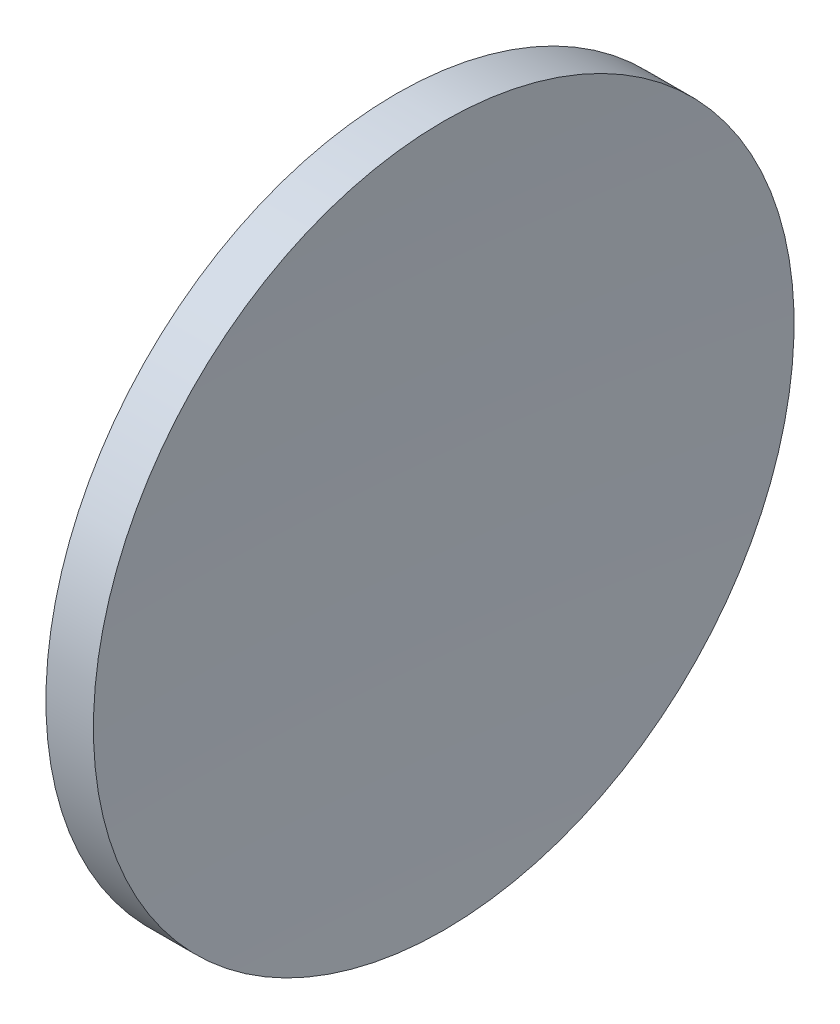
from build123d import *


with BuildPart() as part:
    # 草图1 → 旋转1 (revolve)
    with BuildSketch(Plane.XY):
        with BuildLine():
            Line((247.046493409, 155.433680942), (250.436344506, 155.433680942))
            ThreePointArc((250.436344506, 155.433680942), (249.945712458, 142.937960161), (249.782131121, 130.433680942))
            Line((249.782131121, 130.433680942), (245.282131121, 130.433680942))
            ThreePointArc((245.282131121, 130.433680942), (245.723769571, 142.964772018), (247.046493409, 155.433680942))
        make_face()
    revolve(axis=Axis((231.888982596, 130.433680942, 0), (1, 0, 0)))


solid = part.part
